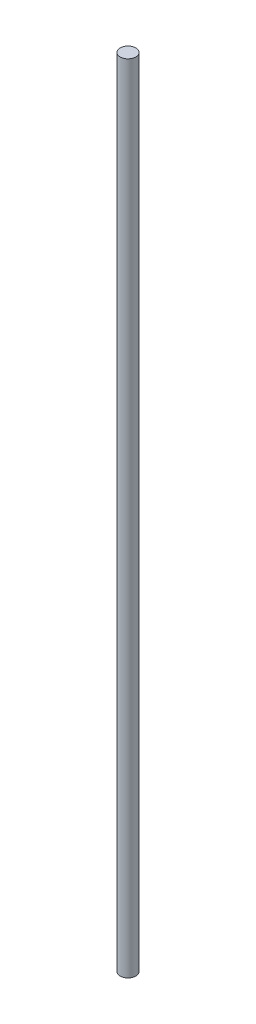
from build123d import *

# Parameters (mm, degrees)
SKETCH1_R           = 4
BOSS_EXTRUDE1_DEPTH = 405


with BuildPart() as part:
    # Sketch1 → Boss-Extrude1 (new body)
    with BuildSketch(Plane(origin=(0, 0, 0), x_dir=(1, 0, 0), z_dir=(0, 1, 0))):
        Circle(SKETCH1_R)
    extrude(amount=BOSS_EXTRUDE1_DEPTH)


solid = part.part
